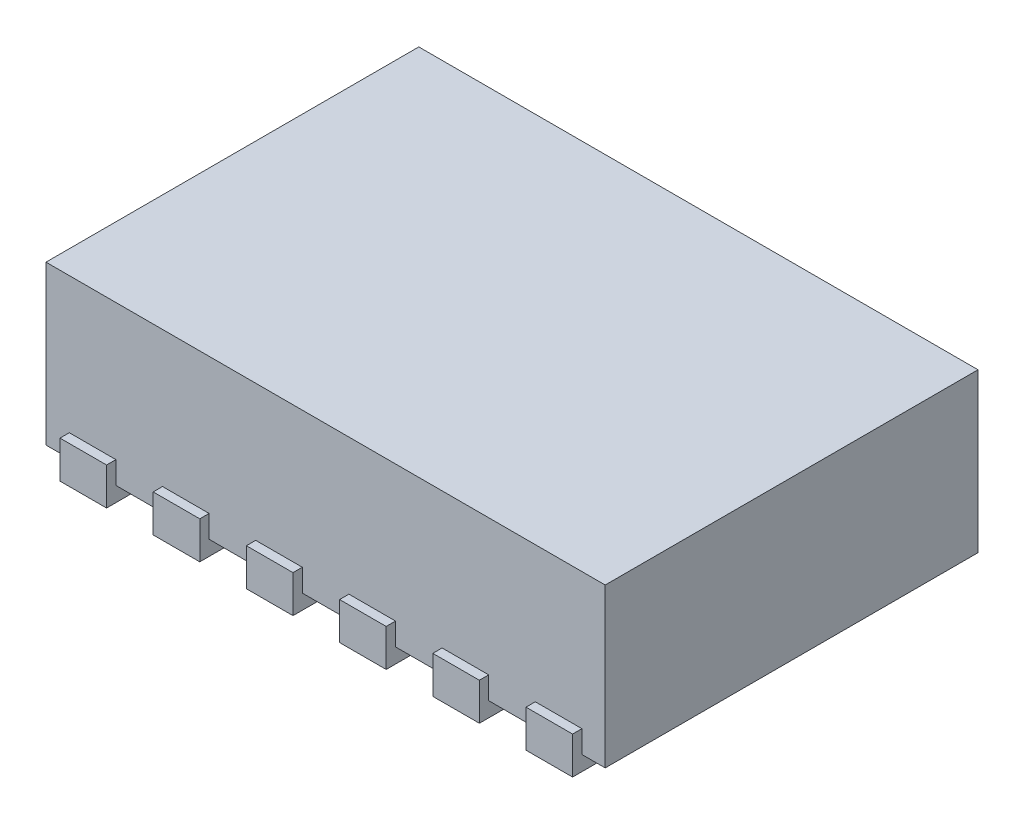
from build123d import *

# Parameters (mm, degrees)
SKETCH1_W           = 3
SKETCH1_H           = 2
BOSS_EXTRUDE1_DEPTH = 0.85
BOSS_EXTRUDE2_START = 0.08
SKETCH2_W           = 0.25
SKETCH2_H           = 0.3
BOSS_EXTRUDE2_DEPTH = 0.2


with BuildPart() as part:
    # Sketch1 → Boss-Extrude1 (new body)
    with BuildSketch(Plane(origin=(0, 0, 0), x_dir=(1, 0, 0), z_dir=(0, 1, 0))):
        with Locations((1.5, 1)):
            Rectangle(SKETCH1_W, SKETCH1_H)
    extrude(amount=BOSS_EXTRUDE1_DEPTH)

    # Sketch2 → Boss-Extrude2 (add)
    with BuildSketch(Plane.XZ.offset(BOSS_EXTRUDE2_START)):
        Polygon((2.5, -0.65), (0.5, -0.65), (0.5, -1.25), (0.6, -1.35), (2.5, -1.35), align=None)
        with Locations((2.25, -0.1)):
            Rectangle(SKETCH2_W, SKETCH2_H)
        with Locations((2.25, -1.9)):
            Rectangle(SKETCH2_W, SKETCH2_H)
        with Locations((1.75, -0.1)):
            Rectangle(SKETCH2_W, SKETCH2_H)
        with Locations((2.75, -0.1)):
            Rectangle(SKETCH2_W, SKETCH2_H)
        with Locations((1.75, -1.9)):
            Rectangle(SKETCH2_W, SKETCH2_H)
        with Locations((2.75, -1.9)):
            Rectangle(SKETCH2_W, SKETCH2_H)
        with Locations((1.25, -0.1)):
            Rectangle(SKETCH2_W, SKETCH2_H)
        with Locations((1.25, -1.9)):
            Rectangle(SKETCH2_W, SKETCH2_H)
        with Locations((0.75, -1.9)):
            Rectangle(SKETCH2_W, SKETCH2_H)
        with Locations((0.25, -1.9)):
            Rectangle(SKETCH2_W, SKETCH2_H)
        with Locations((0.75, -0.1)):
            Rectangle(SKETCH2_W, SKETCH2_H)
        with Locations((0.25, -0.1)):
            Rectangle(SKETCH2_W, SKETCH2_H)
    extrude(amount=-BOSS_EXTRUDE2_DEPTH)


solid = part.part
